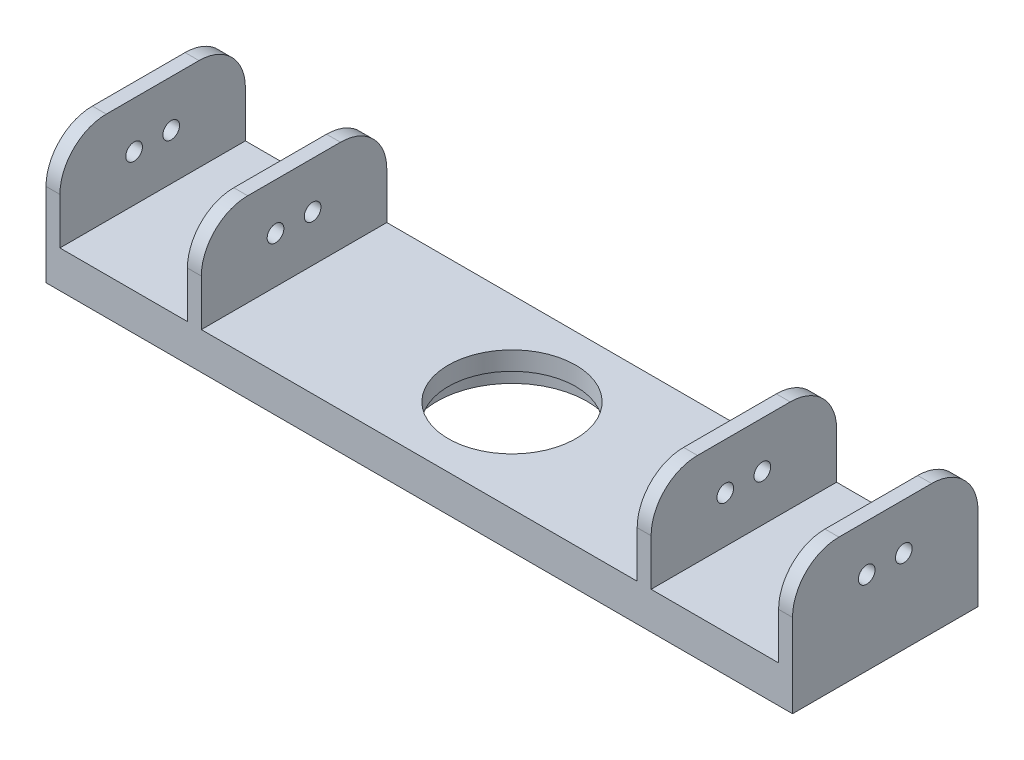
from build123d import *

# Parameters (mm, degrees)
SKETCH1_W               = 161
SKETCH1_H               = 40
BOSS_EXTRUDE1_DEPTH     = 8
SKETCH2_W               = 3
SKETCH2_H               = 40
BOSS_EXTRUDE2_DEPTH     = 20
SKETCH3_R               = 16.2
CUT_EXTRUDE1_DEPTH      = 4
SKETCH4_R               = 1.8
CUT_EXTRUDE2_DEPTH      = 1
CUT_EXTRUDE2_DEPTH_BACK = 162
CUT_EXTRUDE3_REACH      = 26
SKETCH5_R               = 13.75
FILLET1_R               = 10


with BuildPart() as part:
    # Sketch1 → Boss-Extrude1 (new body)
    with BuildSketch(Plane(origin=(0, 0, 0), x_dir=(1, 0, 0), z_dir=(0, 1, 0))):
        Rectangle(SKETCH1_W, SKETCH1_H)
    extrude(amount=BOSS_EXTRUDE1_DEPTH)

    # Sketch2 → Boss-Extrude2 (add)
    with BuildSketch(Plane(origin=(0, 8, 0), x_dir=(1, 0, 0), z_dir=(0, 1, 0))):
        with Locations((-48.5, 0)):
            Rectangle(SKETCH2_W, SKETCH2_H)
        with Locations((-79, 0)):
            Rectangle(SKETCH2_W, SKETCH2_H)
        with Locations((79, 0)):
            Rectangle(SKETCH2_W, SKETCH2_H)
        with Locations((48.5, 0)):
            Rectangle(SKETCH2_W, SKETCH2_H)
    extrude(amount=BOSS_EXTRUDE2_DEPTH)

    # Sketch3 → Cut-Extrude1 (cut)
    with BuildSketch(Plane.XZ):
        Circle(SKETCH3_R)
    extrude(amount=-CUT_EXTRUDE1_DEPTH, mode=Mode.SUBTRACT)

    # Sketch4 → Cut-Extrude2 (cut, two sides)
    with BuildSketch(Plane.ZY.offset(80.5)) as cut_extrude2_sk:
        with Locations((4, 18)):
            Circle(SKETCH4_R)
        with Locations((-4, 18)):
            Circle(SKETCH4_R)
    extrude(amount=CUT_EXTRUDE2_DEPTH, mode=Mode.SUBTRACT)
    extrude(cut_extrude2_sk.sketch, amount=-CUT_EXTRUDE2_DEPTH_BACK, mode=Mode.SUBTRACT)

    # Sketch5 → Cut-Extrude3 (cut, up to next)
    with BuildSketch(Plane.XZ.offset(-4), mode=Mode.PRIVATE) as cut_extrude3_sk1:
        Circle(SKETCH5_R)
    cut_extrude3_tool1 = extrude(cut_extrude3_sk1.sketch, amount=-CUT_EXTRUDE3_REACH, mode=Mode.PRIVATE) & part.part
    add(cut_extrude3_tool1.solids().sort_by_distance((0, 4, 0))[0], mode=Mode.SUBTRACT)

    # Fillet1
    fillet1_edges = [part.edges().sort_by_distance(p)[0] for p in [
        (-48.5, 28, 20),
        (-48.5, 28, -20),
        (-79, 28, 20),
        (-79, 28, -20),
        (79, 28, -20),
        (79, 28, 20),
        (48.5, 28, -20),
        (48.5, 28, 20),
    ]]
    fillet(fillet1_edges, radius=FILLET1_R)


solid = part.part
